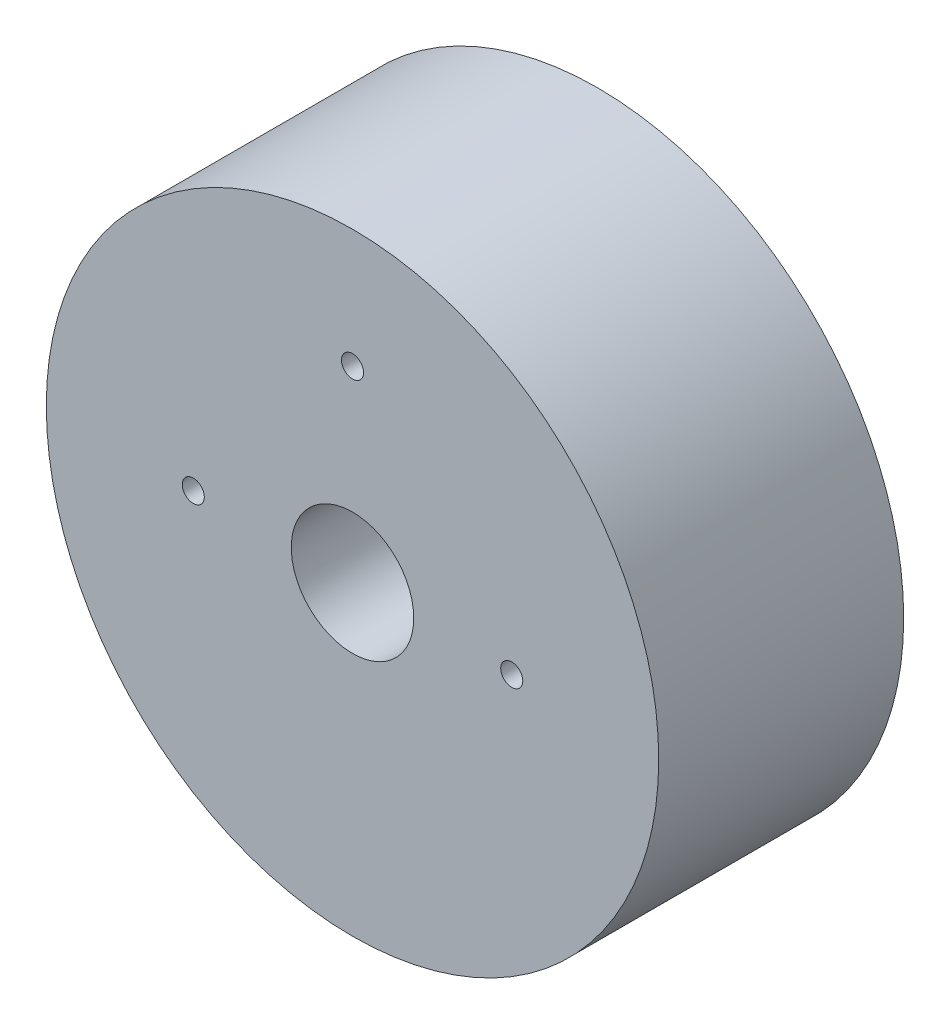
from build123d import *

# Parameters (mm, degrees)
SKETCH1_R           = 63.5
SKETCH1_R_2         = 2.286
BOSS_EXTRUDE1_DEPTH = 50.8
SKETCH2_R           = 12.7
CUT_EXTRUDE1_DEPTH  = 51.8


with BuildPart() as part:
    # Sketch1 → Boss-Extrude1 (new body)
    with BuildSketch(Plane.XY):
        Circle(SKETCH1_R)
        with Locations((-33.02, 0)):
            Circle(SKETCH1_R_2, mode=Mode.SUBTRACT)
        with Locations((33.02, 0)):
            Circle(SKETCH1_R_2, mode=Mode.SUBTRACT)
        with Locations((0, 38.862)):
            Circle(SKETCH1_R_2, mode=Mode.SUBTRACT)
    extrude(amount=BOSS_EXTRUDE1_DEPTH)

    # Sketch2 → Cut-Extrude1 (cut, through all)
    with BuildSketch(Plane.XY.offset(50.8)):
        Circle(SKETCH2_R)
    extrude(amount=-CUT_EXTRUDE1_DEPTH, mode=Mode.SUBTRACT)


solid = part.part
